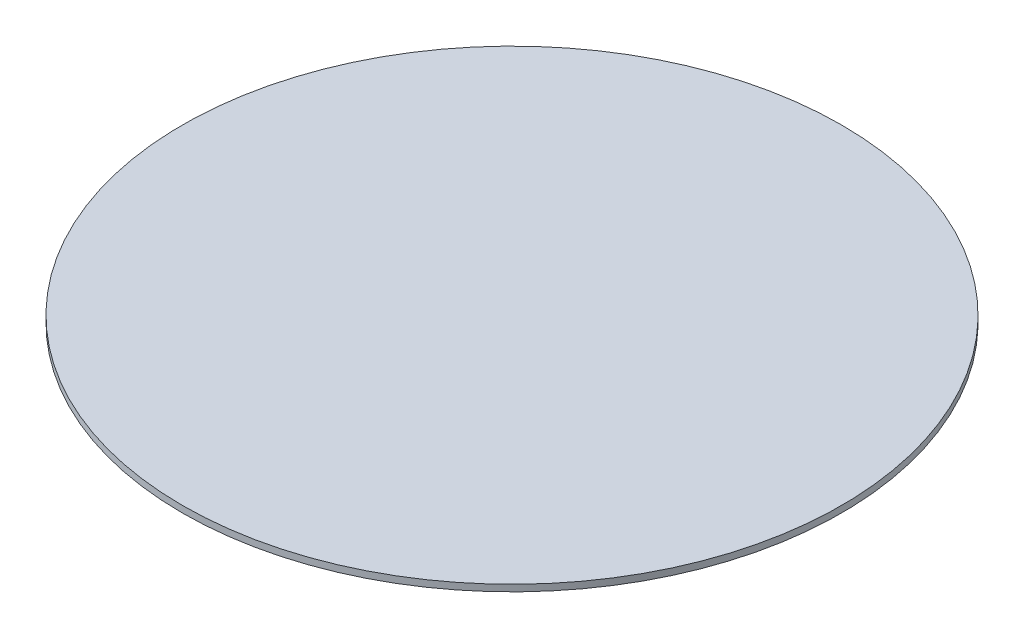
from build123d import *

# Parameters (mm, degrees)
SKIZZE1_R                       = 600
AUFSATZ_LINEAR_AUSTRAGEN1_DEPTH = 12


with BuildPart() as part:
    # Skizze1 → Aufsatz-Linear austragen1 (new body)
    with BuildSketch(Plane(origin=(0, 0, 0), x_dir=(1, 0, 0), z_dir=(0, 1, 0))):
        with Locations(Location((0, 0, 0), (0, 0, 270))):  # turned: the seam where the file's is
            Circle(SKIZZE1_R)
    extrude(amount=AUFSATZ_LINEAR_AUSTRAGEN1_DEPTH)


solid = part.part
